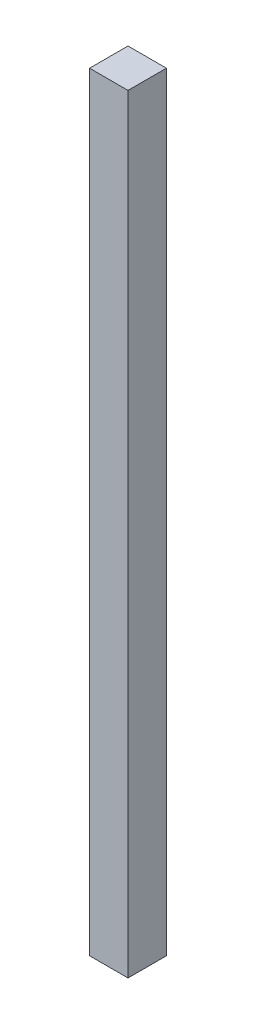
from build123d import *

# Parameters (mm, degrees)
SKETCH1_W           = 25.4
SKETCH1_H           = 25.4
BOSS_EXTRUDE1_DEPTH = 508


with BuildPart() as part:
    # Sketch1 → Boss-Extrude1 (new body)
    with BuildSketch(Plane(origin=(0, 0, 0), x_dir=(1, 0, 0), z_dir=(0, 1, 0))):
        with Locations((12.7, 12.7)):
            Rectangle(SKETCH1_W, SKETCH1_H)
    extrude(amount=BOSS_EXTRUDE1_DEPTH)


solid = part.part
